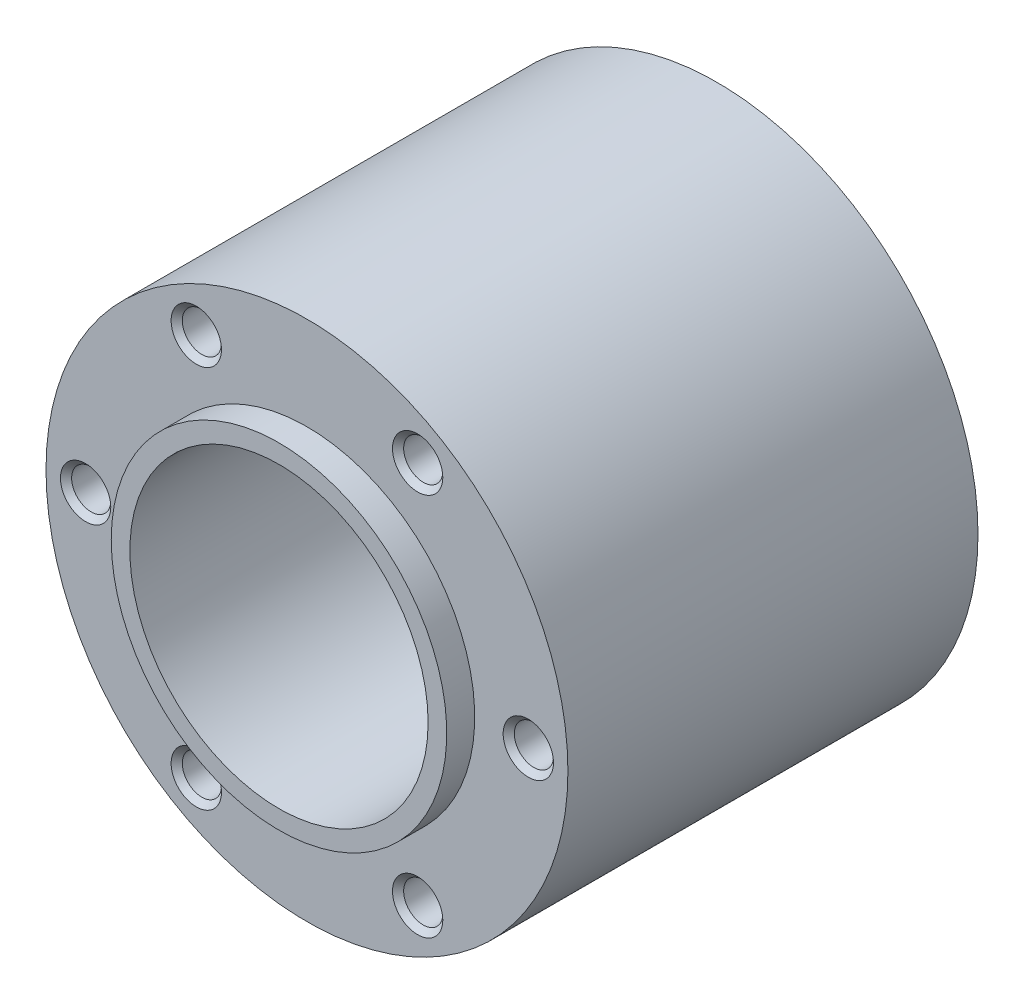
from build123d import *

# Parameters (mm, degrees)
SKETCH_2_R               = 16
CUT_EXTRUDE_1_DEPTH      = 1
CUT_EXTRUDE_1_DEPTH_BACK = 51
HOLE_WIZARD_M51_D        = 4.2
HOLE_WIZARD_M51_DEPTH    = 44.001
PATTERN_CIRCULAR_1_COUNT = 6
CHAMFER_1_SIZE           = 0.6


with BuildPart() as part:
    # Эскиз1 → Повернуть1 (revolve)
    with BuildSketch(Plane(origin=(0, 0, 0), x_dir=(1, 0, 0), z_dir=(0, 1, 0))):
        Polygon((0, 0), (-18, 0), (-18, 3), (-28, 3), (-28, 47), (-18, 47), (-18, 50), (0, 50), align=None)
    revolve(axis=Axis((0, 0, -50), (0, 0, 1)))

    # Эскиз2 → Вырез-Вытянуть1 (cut, two sides)
    with BuildSketch(Plane.XY) as cut_extrude_1_sk:
        Circle(SKETCH_2_R)
    extrude(amount=CUT_EXTRUDE_1_DEPTH, mode=Mode.SUBTRACT)
    extrude(cut_extrude_1_sk.sketch, amount=-CUT_EXTRUDE_1_DEPTH_BACK, mode=Mode.SUBTRACT)

    # Сверление под метчик M51
    with Locations(Plane(origin=(23.75, 0, -3), x_dir=(1, 0, 0), z_dir=(0, 0, 1))):
        with Locations((0, 0)):
            hole_wizard_m51 = Hole(HOLE_WIZARD_M51_D / 2, depth=HOLE_WIZARD_M51_DEPTH)

    # Круговой массив1: Сверление под метчик M51 ×6 about axis
    pattern_circular_1_axis = Axis((0, 0, 0), (0, 0, 1))
    for i in range(1, PATTERN_CIRCULAR_1_COUNT):
        add(hole_wizard_m51.rotate(pattern_circular_1_axis, i * 360 / PATTERN_CIRCULAR_1_COUNT), mode=Mode.SUBTRACT)

    # Фаска1
    chamfer_1_edges = [part.edges().sort_by_distance(p)[0] for p in [
        (25.85, 0, -3),
        (25.85, 0, -47),
        (12.925, -22.386756688, -3),
        (12.925, -22.386756688, -47),
        (-12.925, -22.386756688, -3),
        (-12.925, -22.386756688, -47),
        (-25.85, 0, -3),
        (-25.85, 0, -47),
        (-12.925, 22.386756688, -3),
        (-12.925, 22.386756688, -47),
        (12.925, 22.386756688, -3),
        (12.925, 22.386756688, -47),
    ]]
    chamfer(chamfer_1_edges, length=CHAMFER_1_SIZE)


solid = part.part
